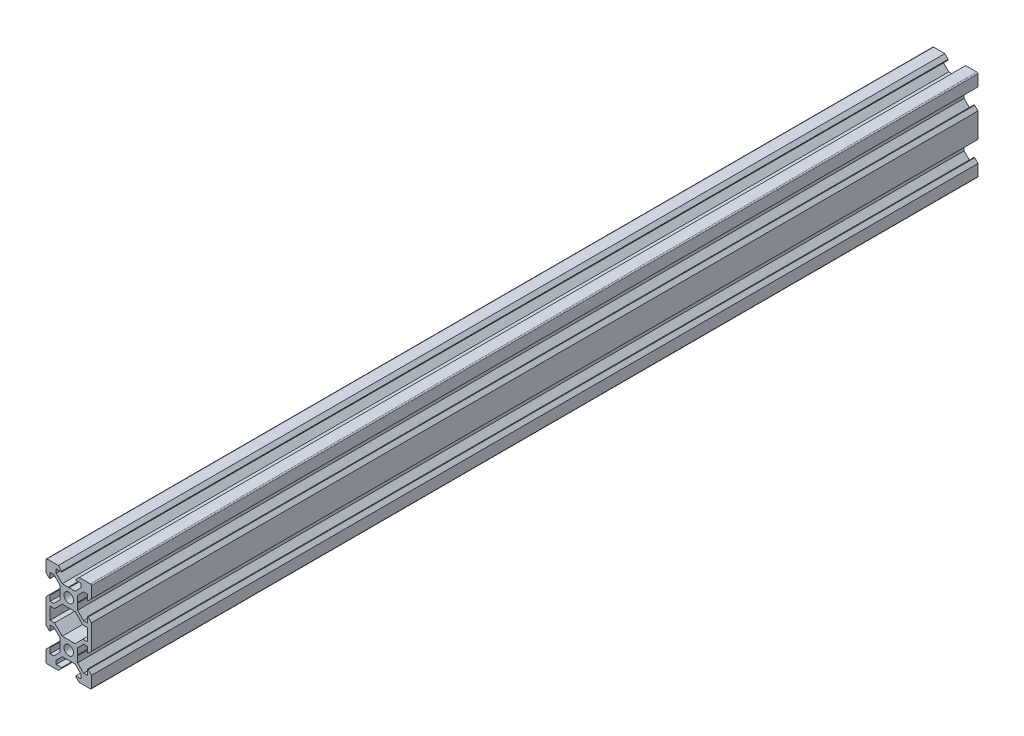
from build123d import *

# Parameters (mm, degrees)
SKETCH1_R           = 2.1
BOSS_EXTRUDE1_DEPTH = 390


with BuildPart() as part:
    # Sketch1 → Boss-Extrude1 (new body)
    with BuildSketch(Plane.XY):
        with BuildLine():
            Line((4.58, -20), (9.5, -20))
            ThreePointArc((9.5, -20), (9.853553391, -19.853553391), (10, -19.5))
            Line((10, -19.5), (10, -14.58))
            Line((10, -14.58), (8.545, -13.125))
            Line((8.545, -13.125), (8.2, -13.125))
            Line((8.2, -13.125), (8.2, -15.5))
            Line((8.2, -15.5), (6.560660172, -15.5))
            Line((6.560660172, -15.5), (3.9, -12.839339828))
            Line((3.9, -12.839339828), (3.9, -10.21))
            Line((3.9, -10.21), (3.69, -10))
            Line((3.69, -10), (3.9, -9.79))
            Line((3.9, -9.79), (3.9, -7.160660172))
            Line((3.9, -7.160660172), (6.560660172, -4.5))
            Line((6.560660172, -4.5), (8.2, -4.5))
            Line((8.2, -4.5), (8.2, -6.875))
            Line((8.2, -6.875), (8.545, -6.875))
            Line((8.545, -6.875), (10, -5.42))
            Line((10, -5.42), (10, 5.42))
            Line((10, 5.42), (8.545, 6.875))
            Line((8.545, 6.875), (8.2, 6.875))
            Line((8.2, 6.875), (8.2, 4.5))
            Line((8.2, 4.5), (6.560660172, 4.5))
            Line((6.560660172, 4.5), (3.9, 7.160660172))
            Line((3.9, 7.160660172), (3.9, 9.79))
            Line((3.9, 9.79), (3.69, 10))
            Line((3.69, 10), (3.9, 10.21))
            Line((3.9, 10.21), (3.9, 12.839339828))
            Line((3.9, 12.839339828), (6.560660172, 15.5))
            Line((6.560660172, 15.5), (8.2, 15.5))
            Line((8.2, 15.5), (8.2, 13.125))
            Line((8.2, 13.125), (8.545, 13.125))
            Line((8.545, 13.125), (10, 14.58))
            Line((10, 14.58), (10, 19.5))
            ThreePointArc((10, 19.5), (9.853553391, 19.853553391), (9.5, 20))
            Line((9.5, 20), (4.58, 20))
            Line((4.58, 20), (3.125, 18.545))
            Line((3.125, 18.545), (3.125, 18.2))
            Line((3.125, 18.2), (5.5, 18.2))
            Line((5.5, 18.2), (5.5, 16.560660172))
            Line((5.5, 16.560660172), (2.839339828, 13.9))
            Line((2.839339828, 13.9), (0.21, 13.9))
            Line((0.21, 13.9), (0, 13.69))
            Line((0, 13.69), (-0.21, 13.9))
            Line((-0.21, 13.9), (-2.839339828, 13.9))
            Line((-2.839339828, 13.9), (-5.5, 16.560660172))
            Line((-5.5, 16.560660172), (-5.5, 18.2))
            Line((-5.5, 18.2), (-3.125, 18.2))
            Line((-3.125, 18.2), (-3.125, 18.545))
            Line((-3.125, 18.545), (-4.58, 20))
            Line((-4.58, 20), (-9.5, 20))
            ThreePointArc((-9.5, 20), (-9.853553391, 19.853553391), (-10, 19.5))
            Line((-10, 19.5), (-10, 14.58))
            Line((-10, 14.58), (-8.545, 13.125))
            Line((-8.545, 13.125), (-8.2, 13.125))
            Line((-8.2, 13.125), (-8.2, 15.5))
            Line((-8.2, 15.5), (-6.560660172, 15.5))
            Line((-6.560660172, 15.5), (-3.9, 12.839339828))
            Line((-3.9, 12.839339828), (-3.9, 10.21))
            Line((-3.9, 10.21), (-3.69, 10))
            Line((-3.69, 10), (-3.9, 9.79))
            Line((-3.9, 9.79), (-3.9, 7.160660172))
            Line((-3.9, 7.160660172), (-6.560660172, 4.5))
            Line((-6.560660172, 4.5), (-8.2, 4.5))
            Line((-8.2, 4.5), (-8.2, 6.875))
            Line((-8.2, 6.875), (-8.545, 6.875))
            Line((-8.545, 6.875), (-10, 5.42))
            Line((-10, 5.42), (-10, -5.42))
            Line((-10, -5.42), (-8.545, -6.875))
            Line((-8.545, -6.875), (-8.2, -6.875))
            Line((-8.2, -6.875), (-8.2, -4.5))
            Line((-8.2, -4.5), (-6.560660172, -4.5))
            Line((-6.560660172, -4.5), (-3.9, -7.160660172))
            Line((-3.9, -7.160660172), (-3.9, -9.79))
            Line((-3.9, -9.79), (-3.69, -10))
            Line((-3.69, -10), (-3.9, -10.21))
            Line((-3.9, -10.21), (-3.9, -12.839339828))
            Line((-3.9, -12.839339828), (-6.560660172, -15.5))
            Line((-6.560660172, -15.5), (-8.2, -15.5))
            Line((-8.2, -15.5), (-8.2, -13.125))
            Line((-8.2, -13.125), (-8.545, -13.125))
            Line((-8.545, -13.125), (-10, -14.58))
            Line((-10, -14.58), (-10, -19.5))
            ThreePointArc((-10, -19.5), (-9.853553391, -19.853553391), (-9.5, -20))
            Line((-9.5, -20), (-4.58, -20))
            Line((-4.58, -20), (-3.125, -18.545))
            Line((-3.125, -18.545), (-3.125, -18.2))
            Line((-3.125, -18.2), (-5.5, -18.2))
            Line((-5.5, -18.2), (-5.5, -16.560660172))
            Line((-5.5, -16.560660172), (-2.839339828, -13.9))
            Line((-2.839339828, -13.9), (-0.21, -13.9))
            Line((-0.21, -13.9), (0, -13.69))
            Line((0, -13.69), (0.21, -13.9))
            Line((0.21, -13.9), (2.839339828, -13.9))
            Line((2.839339828, -13.9), (5.5, -16.560660172))
            Line((5.5, -16.560660172), (5.5, -18.2))
            Line((5.5, -18.2), (3.125, -18.2))
            Line((3.125, -18.2), (3.125, -18.545))
            Line((3.125, -18.545), (4.58, -20))
        make_face()
        with Locations((0, -10)):
            Circle(SKETCH1_R, mode=Mode.SUBTRACT)
        Polygon((-6.239339828, -2.7), (-8.2, -2.7), (-8.2, 2.7), (-6.239339828, 2.7), (-2.839339828, 6.1), (2.839339828, 6.1), (6.239339828, 2.7), (8.2, 2.7), (8.2, -2.7), (6.239339828, -2.7), (2.839339828, -6.1), (-2.839339828, -6.1), align=None, mode=Mode.SUBTRACT)
        with Locations((0, 10)):
            Circle(SKETCH1_R, mode=Mode.SUBTRACT)
    extrude(amount=BOSS_EXTRUDE1_DEPTH)


solid = part.part
